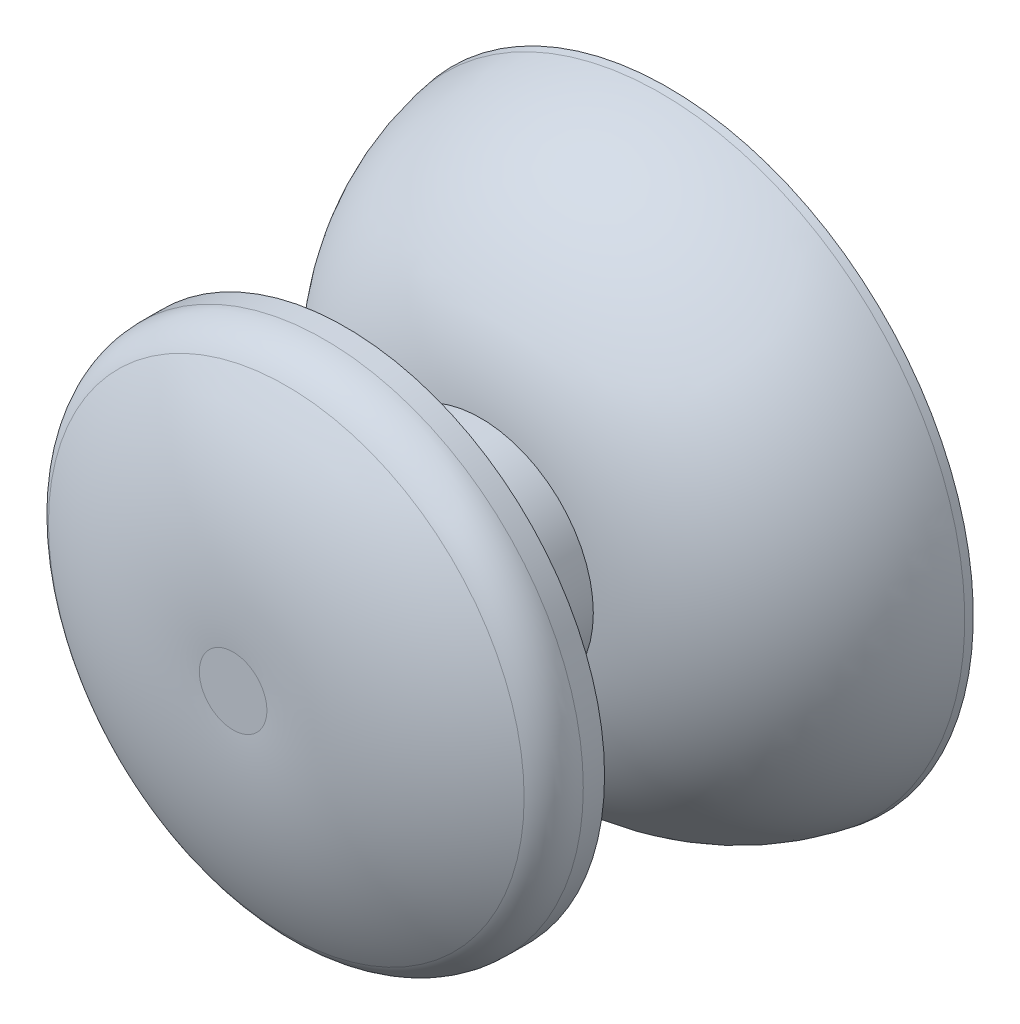
from build123d import *


with BuildPart() as part:
    # 스케치1 → 회전1 (revolve)
    with BuildSketch(Plane.XZ.offset(-12.361086828)):
        with BuildLine():
            Line((56.788605182, 33.75), (55.288605182, 33.75))
            Line((55.288605182, 33.75), (55.288605182, 24.584215849))
            Line((55.288605182, 24.584215849), (56.902385075, 24.584215849))
            Line((56.902385075, 24.584215849), (56.902385075, 19.667107924))
            Line((56.902385075, 19.667107924), (64.110728948, 19.667107924))
            ThreePointArc((64.110728948, 19.667107924), (66.132282487, 17.494751384), (67.260179418, 14.75))
            Line((67.260179418, 14.75), (67.329630852, 14.424330444))
            Line((67.329630852, 14.424330444), (68.842352891, 14.424330444))
            Line((68.842352891, 14.424330444), (68.788605182, 14.75))
            ThreePointArc((68.788605182, 14.75), (65.860000911, 20.153982961), (60.288605182, 22.75))
            Line((60.288605182, 22.75), (60.288605182, 28.75))
            Line((60.288605182, 28.75), (66.788605182, 28.75))
            Line((66.788605182, 28.75), (66.788605182, 29.69501927))
            ThreePointArc((66.788605182, 29.69501927), (66.539331768, 30.661950717), (65.853648759, 31.387851861))
            ThreePointArc((65.853648759, 31.387851861), (61.503658583, 33.269414183), (56.788605182, 33.75))
        make_face()
    revolve(axis=Axis((55.288605182, 12.361086828, 33.770778283), (0, 0, -1)))


solid = part.part
